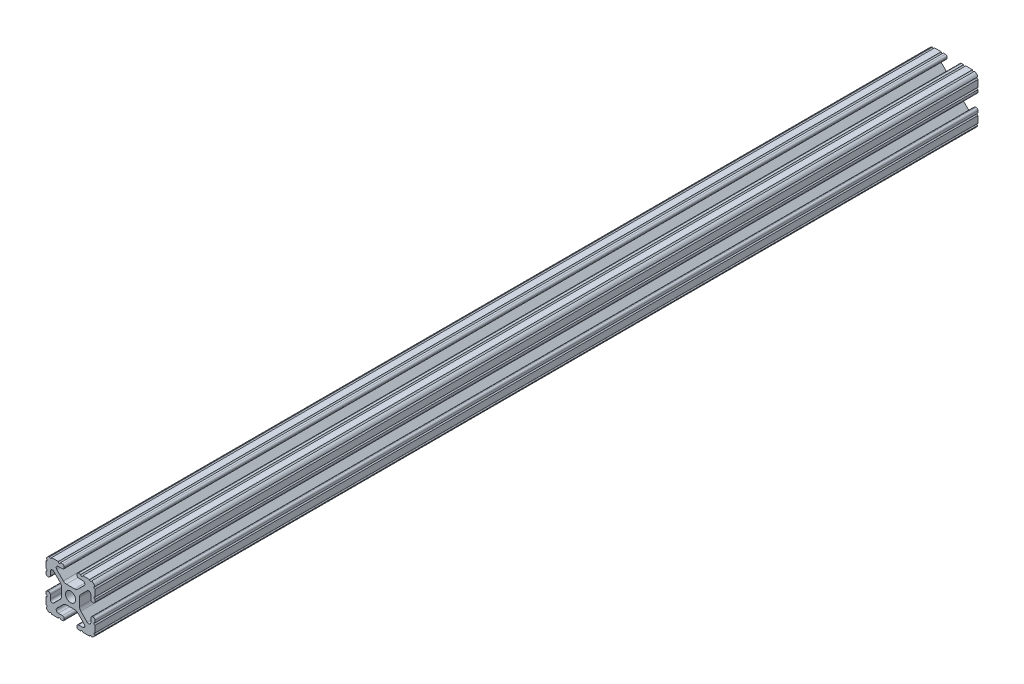
from build123d import *

# Parameters (mm, degrees)
BOSS_EXTRUDE1_DEPTH     = 228.6
SKETCH5_R               = 0.55245
CUT_EXTRUDE1_DEPTH      = 229.6
CUT_EXTRUDE1_DEPTH_BACK = 229.6


with BuildPart() as part:
    # Sketch4 → Boss-Extrude1 (new body, symmetric)
    with BuildSketch(Plane.XY):
        with BuildLine():
            Line((4.190365, -12.7), (10.11729625, -12.7))
            ThreePointArc((10.11729625, -12.7), (11.943543585, -11.943543585), (12.7, -10.11729625))
            Line((12.7, -10.11729625), (12.7, -4.190365))
            ThreePointArc((12.7, -4.190365), (12.42492494, -3.52627506), (11.760835, -3.2512))
            Line((11.760835, -3.2512), (11.429365, -3.2512))
            ThreePointArc((11.429365, -3.2512), (10.76527506, -3.52627506), (10.4902, -4.190365))
            Line((10.4902, -4.190365), (10.4902, -6.348478019))
            ThreePointArc((10.4902, -6.348478019), (9.830707141, -7.335478831), (8.666460301, -7.103895736))
            Line((8.666460301, -7.103895736), (5.299899128, -3.737334563))
            ThreePointArc((5.299899128, -3.737334563), (4.817571085, -3.015479634), (4.6482, -2.16399369))
            Line((4.6482, -2.16399369), (4.6482, 0))
            Line((4.6482, 0), (2.6035, 0))
            ThreePointArc((2.6035, 0), (1.840952505, -1.840952505), (0, -2.6035))
            Line((0, -2.6035), (0, -4.6482))
            Line((0, -4.6482), (2.16399369, -4.6482))
            ThreePointArc((2.16399369, -4.6482), (3.015479634, -4.817571085), (3.737334563, -5.299899128))
            Line((3.737334563, -5.299899128), (7.103895736, -8.666460301))
            ThreePointArc((7.103895736, -8.666460301), (7.335478831, -9.830707141), (6.348478019, -10.4902))
            Line((6.348478019, -10.4902), (4.190365, -10.4902))
            ThreePointArc((4.190365, -10.4902), (3.52627506, -10.76527506), (3.2512, -11.429365))
            Line((3.2512, -11.429365), (3.2512, -11.760835))
            ThreePointArc((3.2512, -11.760835), (3.52627506, -12.42492494), (4.190365, -12.7))
        make_face()
    extrude(amount=BOSS_EXTRUDE1_DEPTH, both=True)

    # Sketch5 → Cut-Extrude1 (cut, two sides)
    with BuildSketch(Plane.XY) as cut_extrude1_sk:
        with Locations((10.356153152, -12.7)):
            Circle(SKETCH5_R)
        with Locations((5.796028019, -12.7)):
            Circle(SKETCH5_R)
        with Locations((12.7, -10.356153152)):
            Circle(SKETCH5_R)
        with Locations((12.7, -5.796028019)):
            Circle(SKETCH5_R)
    extrude(amount=CUT_EXTRUDE1_DEPTH, mode=Mode.SUBTRACT)
    extrude(cut_extrude1_sk.sketch, amount=-CUT_EXTRUDE1_DEPTH_BACK, mode=Mode.SUBTRACT)

    # Mirror1: part across plane


with BuildPart() as part_1:
    add(part.part)
    add(part.part.mirror(Plane(origin=(0, 0, 0), x_dir=(0, 0, 1), z_dir=(1, 0, 0))))

    # Mirror2: part across plane


with BuildPart() as part_2:
    add(part_1.part)
    add(part_1.part.mirror(Plane.ZX))


solid = part_2.part
